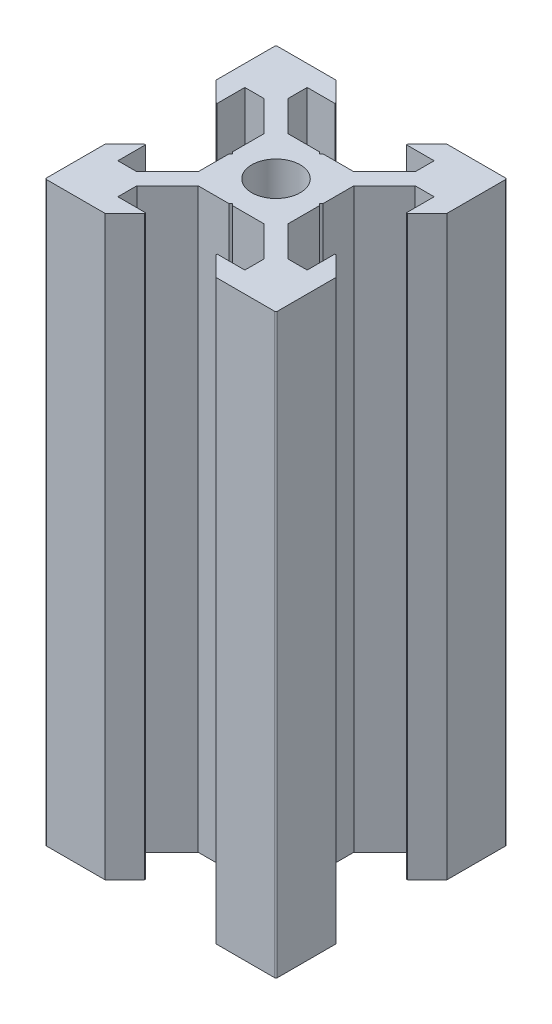
from build123d import *

# Parameters (mm, degrees)
SKETCH3_W           = 20
SKETCH3_H           = 20
SKETCH3_R           = 2.1
BOSS_EXTRUDE1_DEPTH = 50
CUT_EXTRUDE1_DEPTH  = 52.961524227
CIRPATTERN1_COUNT   = 4
CHAMFER2_SIZE       = 1.7
FILLET1_R           = 0.14


with BuildPart() as part:
    # Sketch3 → Boss-Extrude1 (new body)
    with BuildSketch(Plane(origin=(0, 0, 0), x_dir=(1, 0, 0), z_dir=(0, 1, 0))):
        Rectangle(SKETCH3_W, SKETCH3_H)
        Circle(SKETCH3_R, mode=Mode.SUBTRACT)
    extrude(amount=BOSS_EXTRUDE1_DEPTH)

    # Sketch4 → Cut-Extrude1 (cut, symmetric)
    with BuildSketch(Plane(origin=(0, 0, 0), x_dir=(1, 0, 0), z_dir=(0, 1, 0))):
        Polygon((-3.1, 10), (-3.1, 8.2), (-5.5, 8.2), (-5.5, 6.560660172), (-2.839339828, 3.9), (-0.15, 3.9), (0, 3.75), (0.15, 3.9), (2.839339828, 3.9), (5.5, 6.560660172), (5.5, 8.2), (3.1, 8.2), (3.1, 10), align=None)
    cut_extrude1 = extrude(amount=CUT_EXTRUDE1_DEPTH, both=True, mode=Mode.SUBTRACT)

    # CirPattern1: Cut-Extrude1 ×4 about axis
    cirpattern1_axis = Axis((0, 50, 0), (0, -1, 0))
    for i in range(1, CIRPATTERN1_COUNT):
        add(cut_extrude1.rotate(cirpattern1_axis, i * 360 / CIRPATTERN1_COUNT), mode=Mode.SUBTRACT)

    # Chamfer2
    chamfer2_edges = [part.edges().sort_by_distance(p)[0] for p in [
        (3.1, 25, -10),
        (-3.1, 25, -10),
        (-10, 25, -3.1),
        (10, 25, -3.1),
        (10, 25, 3.1),
        (3.1, 25, 10),
        (-3.1, 25, 10),
        (-10, 25, 3.1),
    ]]
    chamfer(chamfer2_edges, length=CHAMFER2_SIZE)

    # Fillet1
    fillet1_edges = [part.edges().sort_by_distance(p)[0] for p in [
        (-10, 25, 10),
        (-10, 25, -10),
        (10, 25, -10),
        (10, 25, 10),
    ]]
    fillet(fillet1_edges, radius=FILLET1_R)


solid = part.part
